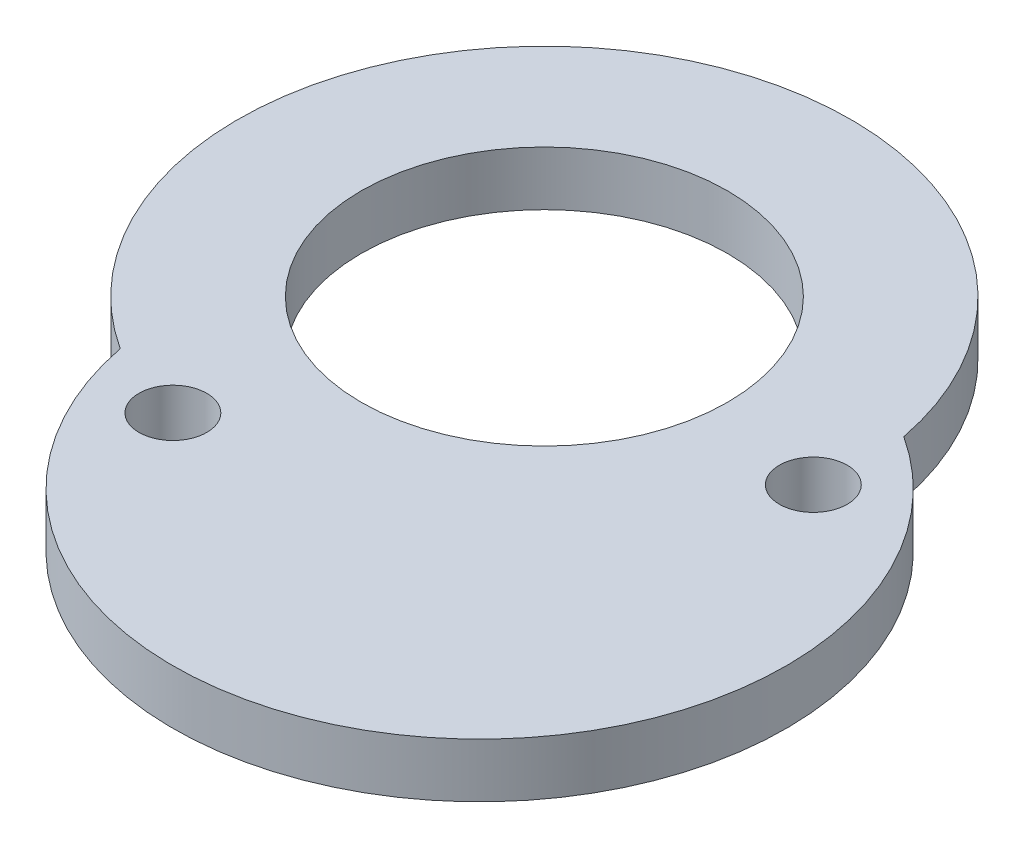
from build123d import *

# Parameters (mm, degrees)
SKETCH_1_R      = 6.75
SKETCH_1_R_2    = 1.25
EXTRUDE_1_DEPTH = 2


with BuildPart() as part:
    # 草图1 → 凸台-拉伸1 (new body)
    with BuildSketch(Plane(origin=(0, 0, 0), x_dir=(1, 0, 0), z_dir=(0, 1, 0))):
        with BuildLine():
            ThreePointArc((11.093218509, 2.151860383), (-6.318879809, 9.36812457), (-6.150763, -9.479352009))
            ThreePointArc((-6.150763, -9.479352009), (11.261335318, -16.695616197), (11.093218509, 2.151860383))
        make_face()
        Circle(SKETCH_1_R, mode=Mode.SUBTRACT)
        with Locations((-3.132469042, -10.556402687)):
            Circle(SKETCH_1_R_2, mode=Mode.SUBTRACT)
        with Locations((10.961169691, -1.050123328)):
            Circle(SKETCH_1_R_2, mode=Mode.SUBTRACT)
    extrude(amount=EXTRUDE_1_DEPTH)


solid = part.part
